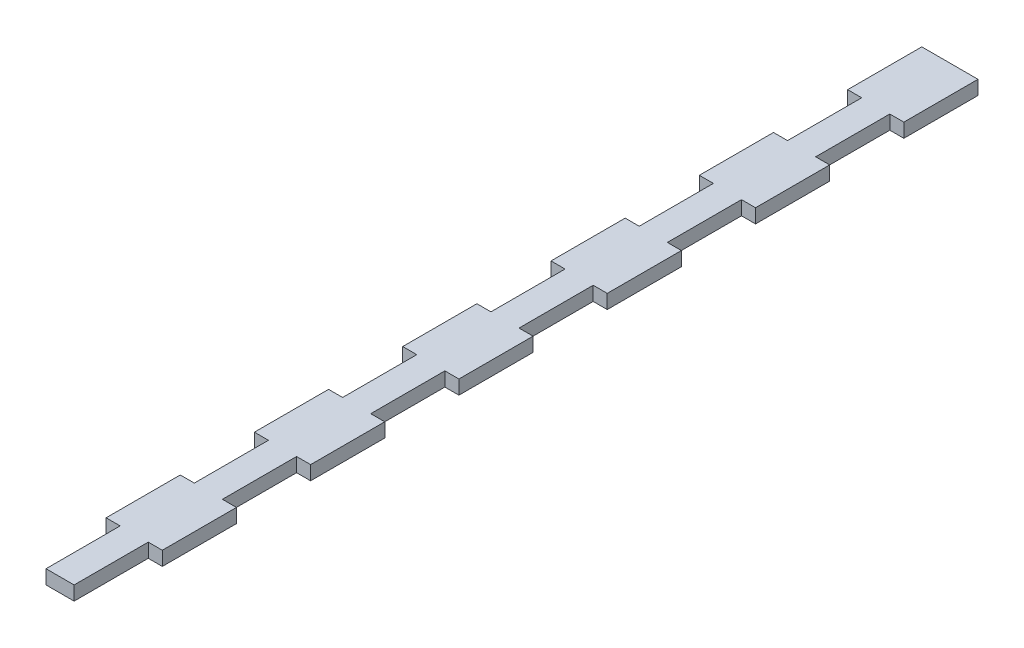
from build123d import *

# Parameters (mm, degrees)
BOSS_EXTRUDE1_DEPTH = 3


with BuildPart() as part:
    # Sketch2 → Boss-Extrude1 (new body)
    with BuildSketch(Plane(origin=(0, 0, 0), x_dir=(1, 0, 0), z_dir=(0, 1, 0))):
        Polygon((-3, -79.166666667), (-3, -95), (3, -95), (3, -79.166666667), (6, -79.166666667), (6, -63.333333333), (3, -63.333333333), (3, -47.5), (6, -47.5), (6, -31.666666667), (3, -31.666666667), (3, -15.833333333), (6, -15.833333333), (6, 0), (3, 0), (3, 15.833333333), (6, 15.833333333), (6, 31.666666667), (3, 31.666666667), (3, 47.5), (6, 47.5), (6, 63.333333333), (3, 63.333333333), (3, 79.166666667), (6, 79.166666667), (6, 95), (-6, 95), (-6, 79.166666667), (-3, 79.166666667), (-3, 63.333333333), (-6, 63.333333333), (-6, 47.5), (-3, 47.5), (-3, 31.666666667), (-6, 31.666666667), (-6, 15.833333333), (-3, 15.833333333), (-3, 0), (-6, 0), (-6, -15.833333333), (-3, -15.833333333), (-3, -31.666666667), (-6, -31.666666667), (-6, -47.5), (-3, -47.5), (-3, -63.333333333), (-6, -63.333333333), (-6, -79.166666667), align=None)
    extrude(amount=BOSS_EXTRUDE1_DEPTH)


solid = part.part
